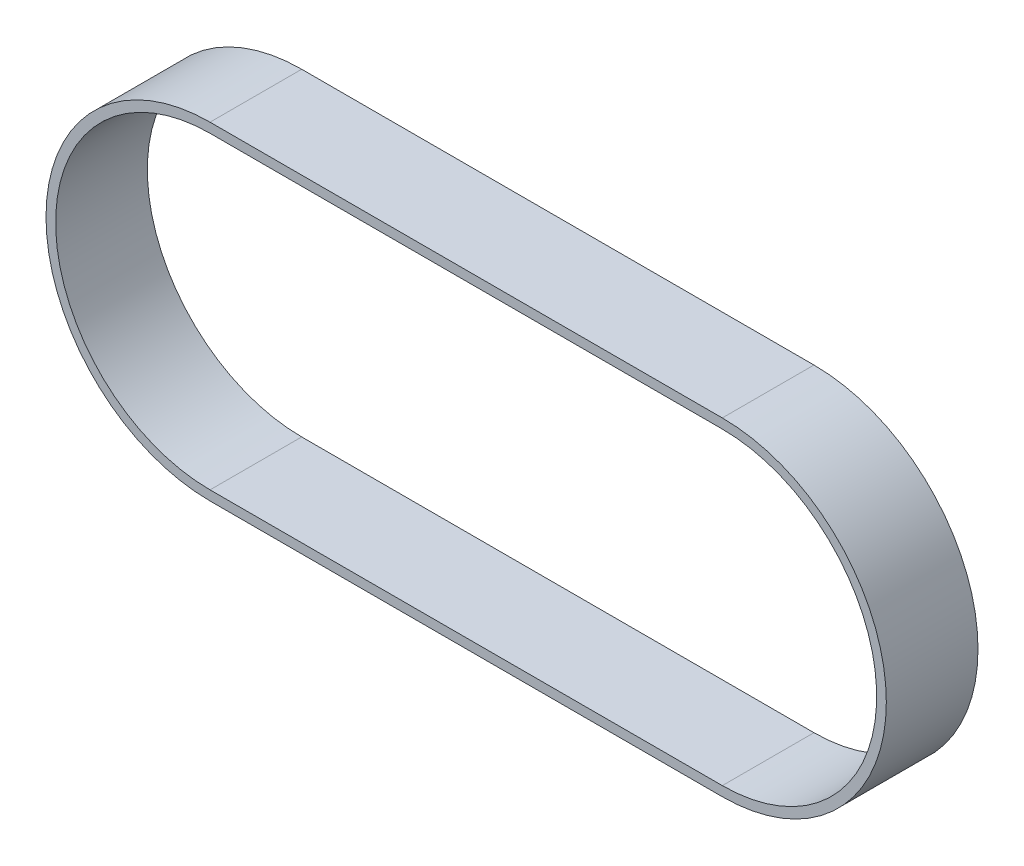
from build123d import *

# Parameters (mm, degrees)
EXTRUDE_THIN1_DEPTH      = 9.5
EXTRUDE_THIN1_DEPTH_BACK = 9.5


with BuildPart() as part:
    # Sketch2 → Extrude-Thin1 (new, two sides)
    with BuildSketch(Plane.XY) as extrude_thin1_sk:
        with BuildLine():
            Line((-106.18, 34), (0, 34))
            ThreePointArc((0, 34), (34, 0), (0, -34))
            Line((0, -34), (-106.18, -34))
            ThreePointArc((-106.18, -34), (-140.18, 0), (-106.18, 34))
        make_face()
        with BuildLine():
            Line((-106.18, 32), (0, 32))
            ThreePointArc((0, 32), (32, 0), (0, -32))
            Line((0, -32), (-106.18, -32))
            ThreePointArc((-106.18, -32), (-138.18, 0), (-106.18, 32))
        make_face(mode=Mode.SUBTRACT)
    extrude(amount=EXTRUDE_THIN1_DEPTH)
    extrude(extrude_thin1_sk.sketch, amount=-EXTRUDE_THIN1_DEPTH_BACK)


solid = part.part
